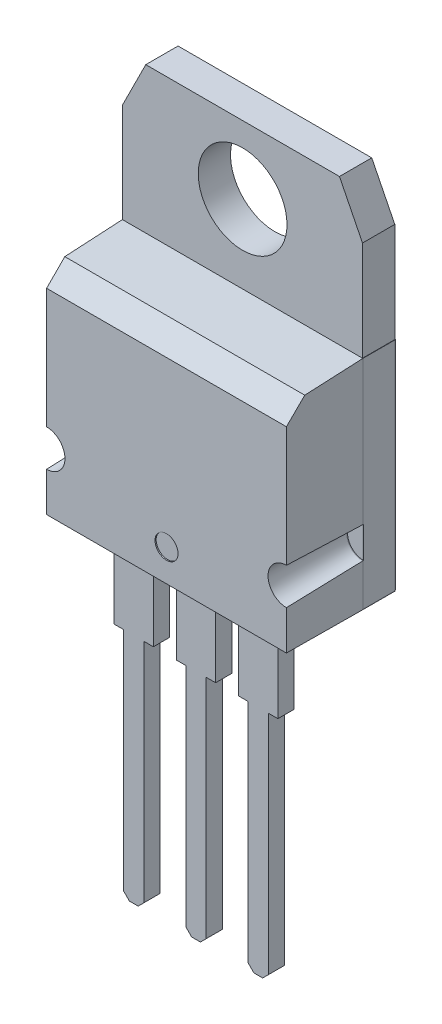
from build123d import *

# Parameters (mm, degrees)
SKETCH1_R             = 1.925
BOSS_EXTRUDE1_DEPTH   = 1.4
SKETCH2_W             = 10.4
SKETCH2_H             = 9.25
BOSS_EXTRUDE2_DEPTH   = 3.3
CHAMFER1_SIZE         = 0.75
DRAFT7_ANGLE          = 3
DRAFT8_ANGLE          = 0.25
SKETCH4_W             = 0.014399058
SKETCH4_H             = 9.422945672
BOSS_EXTRUDE4_DEPTH   = 1.4
BOSS_EXTRUDE4_2_DEPTH = 1.4
SKETCH5_R             = 0.795641545
CUT_EXTRUDE1_DEPTH    = 3.33
CUT_EXTRUDE1_TAPER    = 2
BOSS_EXTRUDE6_DEPTH   = 0.025
BOSS_EXTRUDE7_DEPTH   = 0.7
BOSS_EXTRUDE7_2_DEPTH = 0.7
BOSS_EXTRUDE7_3_DEPTH = 0.7
DRAFT16_ANGLE         = 0.25
SKETCH16_W            = 10.428798116
SKETCH16_H            = 0.014399058
BOSS_EXTRUDE8_DEPTH   = 1.4
SKETCH17_R            = 0.5
CUT_EXTRUDE2_DEPTH    = 0.05


with BuildPart() as part:
    # Sketch1 → Boss-Extrude1 (new body)
    with BuildSketch(Plane.XY):
        Polygon((-5.2, 8.935228045), (-4.2, 10.935228045), (4.2, 10.935228045), (5.2, 8.935228045), (5.2, -4.814771955), (-5.2, -4.814771955), align=None)
        with Locations((0, 7.985228045)):
            Circle(SKETCH1_R, mode=Mode.SUBTRACT)
    extrude(amount=BOSS_EXTRUDE1_DEPTH)


with BuildPart() as body_2:
    # Sketch2 → Boss-Extrude2 (new body)
    with BuildSketch(Plane.XY.offset(1.4)):
        with Locations((0, -0.189771955)):
            Rectangle(SKETCH2_W, SKETCH2_H)
    extrude(amount=BOSS_EXTRUDE2_DEPTH)

    # Chamfer1
    chamfer1_edges = [body_2.edges().sort_by_distance(p)[0] for p in [
        (0, 4.435228045, 4.7),
    ]]
    chamfer(chamfer1_edges, length=CHAMFER1_SIZE)

    # Draft7
    draft7_faces = [body_2.faces().sort_by_distance(p)[0] for p in [
        (0, 4.435228045, 2.675),
    ]]
    draft(draft7_faces, Plane.XY.offset(4.7), DRAFT7_ANGLE)

    # Draft8
    draft8_faces = [body_2.faces().sort_by_distance(p)[0] for p in [
        (5.2, -0.188670245, 3.031373156),
        (-5.2, -0.188670245, 3.031373156),
    ]]
    draft(draft8_faces, Plane.XY.offset(4.7), DRAFT8_ANGLE)


with BuildPart() as body_3:
    # Sketch4 → Boss-Extrude4 (new body)
    with BuildSketch(Plane(origin=(0, 0, 1.4), x_dir=(-1, 0, 0), z_dir=(0, 0, -1))):
        with Locations((-5.207199529, -0.103299119)):
            Rectangle(SKETCH4_W, SKETCH4_H)
    extrude(amount=BOSS_EXTRUDE4_DEPTH)


with BuildPart() as body_4:
    # Sketch4 → Boss-Extrude4 2 (new body)
    with BuildSketch(Plane(origin=(0, 0, 1.4), x_dir=(-1, 0, 0), z_dir=(0, 0, -1))):
        with Locations((5.207199529, -0.103299119)):
            Rectangle(SKETCH4_W, SKETCH4_H)
    extrude(amount=BOSS_EXTRUDE4_2_DEPTH)


with BuildPart() as cut_extrude1_tool:
    # Sketch5 → Cut-Extrude1 (new body)
    with BuildSketch(Plane.XY.offset(4.7)):
        with Locations((-5.2, -2.314771955)):
            Circle(SKETCH5_R)
        with Locations((5.2, -2.314771955)):
            Circle(SKETCH5_R)
    extrude(amount=-CUT_EXTRUDE1_DEPTH, taper=CUT_EXTRUDE1_TAPER)


with BuildPart() as part_1:
    add(part.part)

    # Cut-Extrude1: cut by cut_extrude1_tool
    add(cut_extrude1_tool.part, mode=Mode.SUBTRACT)


with BuildPart() as body_2_1:
    add(body_2.part)

    # Cut-Extrude1: cut by cut_extrude1_tool
    add(cut_extrude1_tool.part, mode=Mode.SUBTRACT)

    # Draft16
    draft16_faces = [body_2_1.faces().sort_by_distance(p)[0] for p in [
        (0, -4.814771955, 3.049239564),
    ]]
    draft(draft16_faces, Plane.XY.offset(4.7), DRAFT16_ANGLE)

    # Sketch17 → Cut-Extrude2 (cut)
    with BuildSketch(Plane.XY.offset(4.7)):
        with Locations((0, -3.431055698)):
            Circle(SKETCH17_R)
    extrude(amount=-CUT_EXTRUDE2_DEPTH, mode=Mode.SUBTRACT)


with BuildPart() as body_3_1:
    add(body_3.part)

    # Cut-Extrude1: cut by cut_extrude1_tool
    add(cut_extrude1_tool.part, mode=Mode.SUBTRACT)


with BuildPart() as body_4_1:
    add(body_4.part)

    # Cut-Extrude1: cut by cut_extrude1_tool
    add(cut_extrude1_tool.part, mode=Mode.SUBTRACT)


with BuildPart() as body_5:
    # Sketch6 → Boss-Extrude6 (new body)
    with BuildSketch(Plane(origin=(0, 0, 0), x_dir=(-1, 0, 0), z_dir=(0, 0, -1))):
        Polygon((-5.2, 4.608173717), (-2.516415683, 4.608173717), (-2.516415683, 3.858173717), (-3.7, 3.858173717), (-3.7, -2.207251306), (-4.45, -2.207251306), (-4.45, -3.039821774), (-4.45, -3.064771955), (-4.310560576, -3.064771955), (4.310560576, -3.064771955), (4.45, -3.064771955), (4.45, -3.039821774), (4.45, -2.207251306), (3.7, -2.207251306), (3.7, 3.858173717), (2.516415683, 3.858173717), (2.516415683, 4.608173717), (5.2, 4.608173717), (5.2, -4.814771955), (-5.2, -4.814771955), align=None)
    extrude(amount=BOSS_EXTRUDE6_DEPTH)


with BuildPart() as body_6:
    # Sketch10 → Boss-Extrude7 (new body)
    with BuildSketch(Plane(origin=(0, 0, 2.72), x_dir=(-1, 0, 0), z_dir=(0, 0, -1))):
        Polygon((-0.85, -4.814771955), (0.85, -4.814771955), (0.85, -8.744771955), (0.44, -8.744771955), (0.44, -18.564771955), (0.19, -18.814771955), (-0.19, -18.814771955), (-0.44, -18.564771955), (-0.44, -8.744771955), (-0.85, -8.744771955), align=None)
    extrude(amount=-BOSS_EXTRUDE7_DEPTH)


with BuildPart() as body_7:
    # Sketch10 → Boss-Extrude7 2 (new body)
    with BuildSketch(Plane(origin=(0, 0, 2.72), x_dir=(-1, 0, 0), z_dir=(0, 0, -1))):
        Polygon((1.85, -4.814771955), (1.85, -8.744771955), (2.26, -8.744771955), (2.26, -18.564771955), (2.51, -18.814771955), (2.89, -18.814771955), (3.14, -18.564771955), (3.14, -8.744771955), (3.55, -8.744771955), (3.55, -4.814771955), align=None)
    extrude(amount=-BOSS_EXTRUDE7_2_DEPTH)


with BuildPart() as body_8:
    # Sketch10 → Boss-Extrude7 3 (new body)
    with BuildSketch(Plane(origin=(0, 0, 2.72), x_dir=(-1, 0, 0), z_dir=(0, 0, -1))):
        Polygon((-3.55, -4.814771955), (-3.55, -8.744771955), (-3.14, -8.744771955), (-3.14, -18.564771955), (-2.89, -18.814771955), (-2.51, -18.814771955), (-2.26, -18.564771955), (-2.26, -8.744771955), (-1.85, -8.744771955), (-1.85, -4.814771955), align=None)
    extrude(amount=-BOSS_EXTRUDE7_3_DEPTH)


with BuildPart() as body_9:
    # Sketch16 → Boss-Extrude8 (new body)
    with BuildSketch(Plane(origin=(0, 0, 1.4), x_dir=(-1, 0, 0), z_dir=(0, 0, -1))):
        with Locations((0, -4.821971484)):
            Rectangle(SKETCH16_W, SKETCH16_H)
    extrude(amount=BOSS_EXTRUDE8_DEPTH)


solid = Compound([part_1.part, body_2_1.part, body_3_1.part, body_4_1.part, body_5.part, body_6.part, body_7.part, body_8.part, body_9.part])
